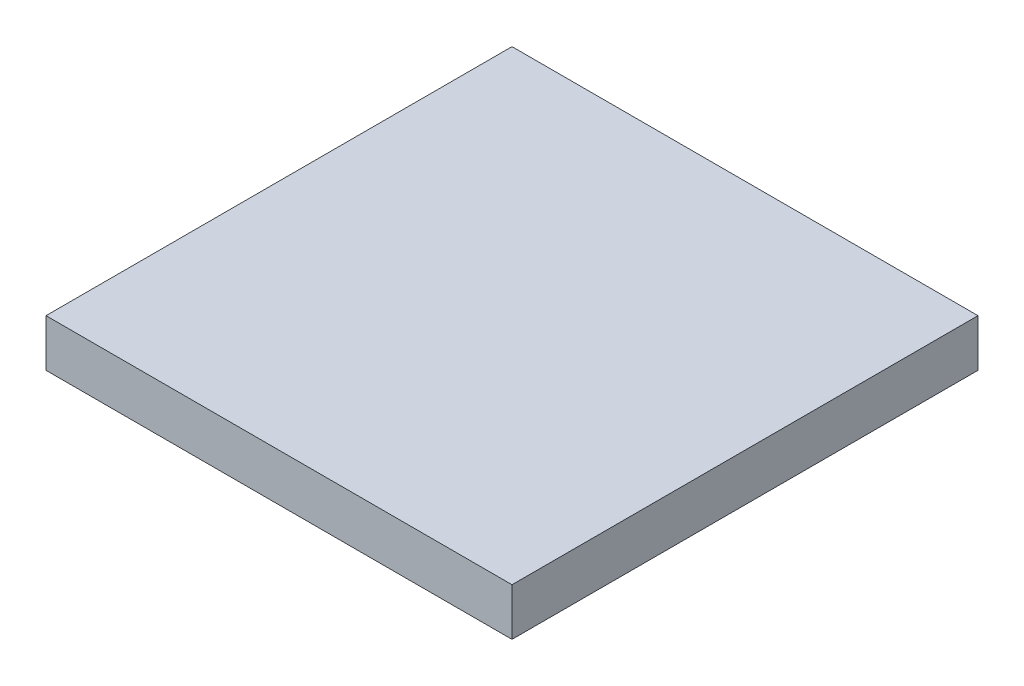
from build123d import *

# Parameters (mm, degrees)
SKETCH8_W           = 31
SKETCH8_H           = 31
BOSS_EXTRUDE4_DEPTH = 3.15


with BuildPart() as part:
    # Sketch8 → Boss-Extrude4 (new body)
    with BuildSketch(Plane(origin=(0, 0, 0), x_dir=(1, 0, 0), z_dir=(0, 1, 0))):
        Rectangle(SKETCH8_W, SKETCH8_H)
    extrude(amount=BOSS_EXTRUDE4_DEPTH)


solid = part.part
